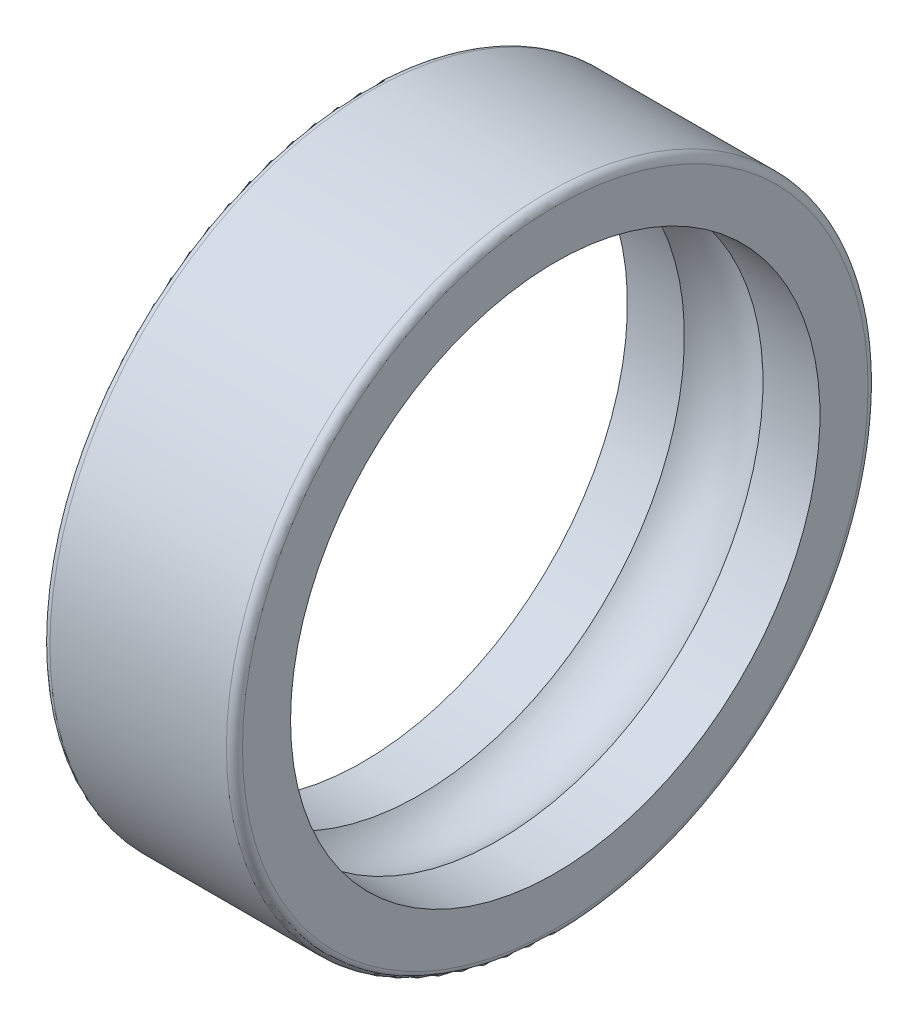
from build123d import *


with BuildPart() as part:
    # Sketch1 → Revolve1 (revolve)
    with BuildSketch(Plane.XY):
        with BuildLine():
            Line((-0.831932773, 2.5), (-0.831932773, 5.5))
            ThreePointArc((-0.831932773, 5.5), (-0.685486164, 5.853553391), (-0.331932773, 6))
            Line((-0.331932773, 6), (10.668067227, 6))
            ThreePointArc((10.668067227, 6), (11.021620617, 5.853553391), (11.168067227, 5.5))
            Line((11.168067227, 5.5), (11.168067227, 2.5))
            Line((11.168067227, 2.5), (7.61755697, 2.5))
            ThreePointArc((7.61755697, 2.5), (5.168067227, 3.5), (2.718577484, 2.5))
            Line((2.718577484, 2.5), (-0.831932773, 2.5))
        make_face()
    revolve(axis=Axis((-10.537576458, -14, 0), (1, 0, 0)))


solid = part.part
